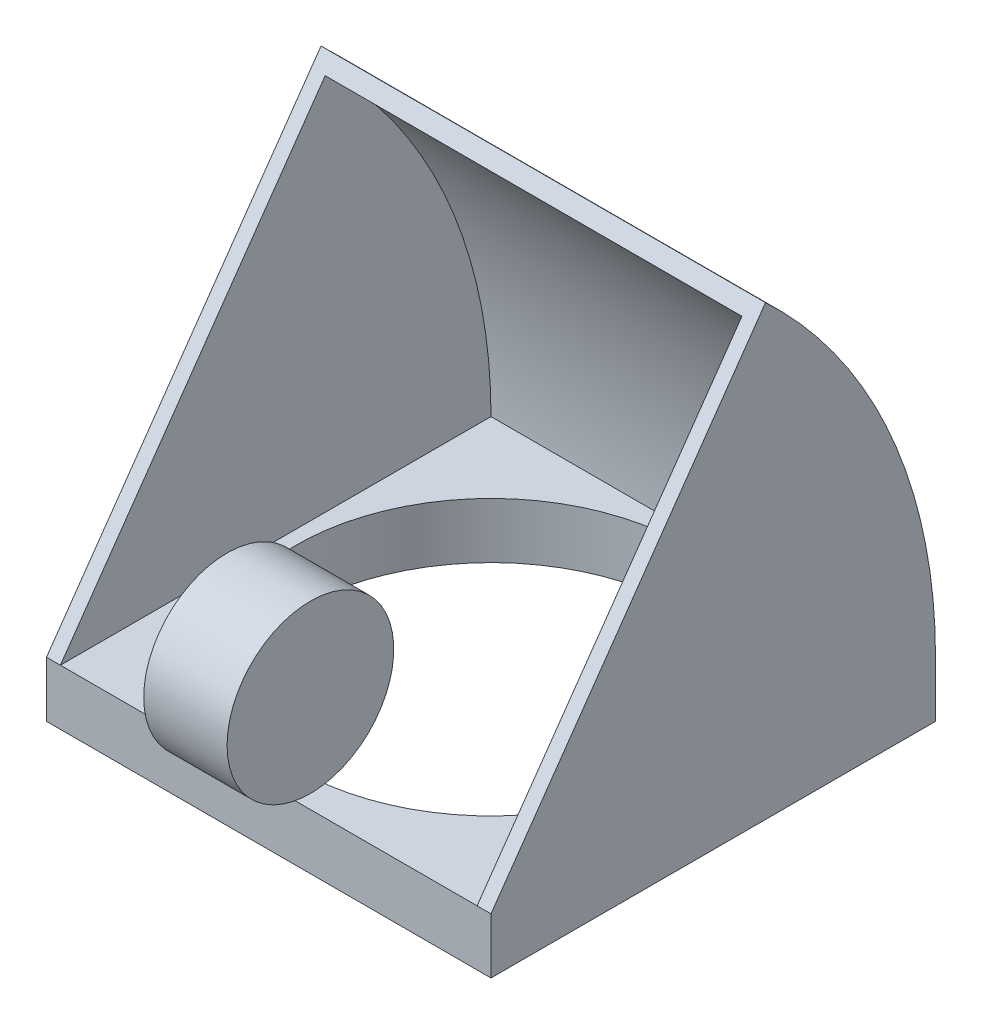
from build123d import *

# Parameters (mm, degrees)
SKETCH2_W               = 203.2
SKETCH2_H               = 203.2
SKETCH2_R               = 88.9
BOSS_EXTRUDE1_DEPTH     = 25.4
BOSS_EXTRUDE2_DEPTH     = 203.2
CUT_EXTRUDE3_REACH      = 307.75
CUT_EXTRUDE3_END_RADIUS = 239.183333333
SKETCH5_W               = 190.5
SKETCH5_H               = 172.872926977
BOSS_EXTRUDE3_DEPTH     = 19.05


with BuildPart() as part:
    # Sketch2 → Boss-Extrude1 (new body)
    with BuildSketch(Plane(origin=(0, 0, 0), x_dir=(1, 0, 0), z_dir=(0, 1, 0))):
        Rectangle(SKETCH2_W, SKETCH2_H)
        with Locations(Location((0, 0, 0), (0, 0, 270))):
            Circle(SKETCH2_R, mode=Mode.SUBTRACT)
    extrude(amount=BOSS_EXTRUDE1_DEPTH)

    # Sketch3 → Boss-Extrude2 (add)
    with BuildSketch(Plane(origin=(101.6, 0, 0), x_dir=(0, 0, -1), z_dir=(1, 0, 0))):
        with BuildLine():
            Line((-101.6, 25.4), (23.893244489, 204.622926977))
            ThreePointArc((23.893244489, 204.622926977), (81.337211626, 123.071896426), (101.6, 25.4))
            Line((101.6, 25.4), (-101.6, 25.4))
        make_face()
    extrude(amount=-BOSS_EXTRUDE2_DEPTH)

    # Cut-Extrude3: up to this cylinder (the profile starts inside it)
    cut_extrude3_end = Plane(origin=(0, 25.4, 143.933333333), z_dir=(1, 0, 0)) * Cylinder(CUT_EXTRUDE3_END_RADIUS, 1094.866666667, mode=Mode.PRIVATE)
    # Sketch5 → Cut-Extrude3 (cut, up to the surface)
    with BuildSketch(Plane.XY.offset(101.6), mode=Mode.PRIVATE) as cut_extrude3_sk1:
        with Locations((0, 111.836463489)):
            Rectangle(SKETCH5_W, SKETCH5_H)
    cut_extrude3_tool1 = extrude(cut_extrude3_sk1.sketch, amount=-CUT_EXTRUDE3_REACH, mode=Mode.PRIVATE) & cut_extrude3_end
    add(cut_extrude3_tool1.solids().sort_by_distance((0, 111.836463, 101.6))[0], mode=Mode.SUBTRACT)


with BuildPart() as body_2:
    # Sketch6 → Boss-Extrude3 (new, symmetric)
    with BuildSketch(Plane(origin=(0, 0, 0), x_dir=(0, 0, -1), z_dir=(1, 0, 0))):
        with BuildLine():
            ThreePointArc((-63.5, 69.85), (-63.744790714, 74.161975174), (-64.476017317, 78.41854187))
            Line((-64.476017317, 78.41854187), (-96.954645689, 32.0342535))
            ThreePointArc((-96.954645689, 32.0342535), (-73.06407528, 44.604980682), (-63.5, 69.85))
        make_face()
        with BuildLine():
            Line((-96.954645689, 32.0342535), (-64.476017317, 78.41854187))
            ThreePointArc((-64.476017317, 78.41854187), (-132.809692887, 91.703262225), (-96.954645689, 32.0342535))
        make_face()
    extrude(amount=BOSS_EXTRUDE3_DEPTH, both=True)


solid = Compound([part.part, body_2.part])
